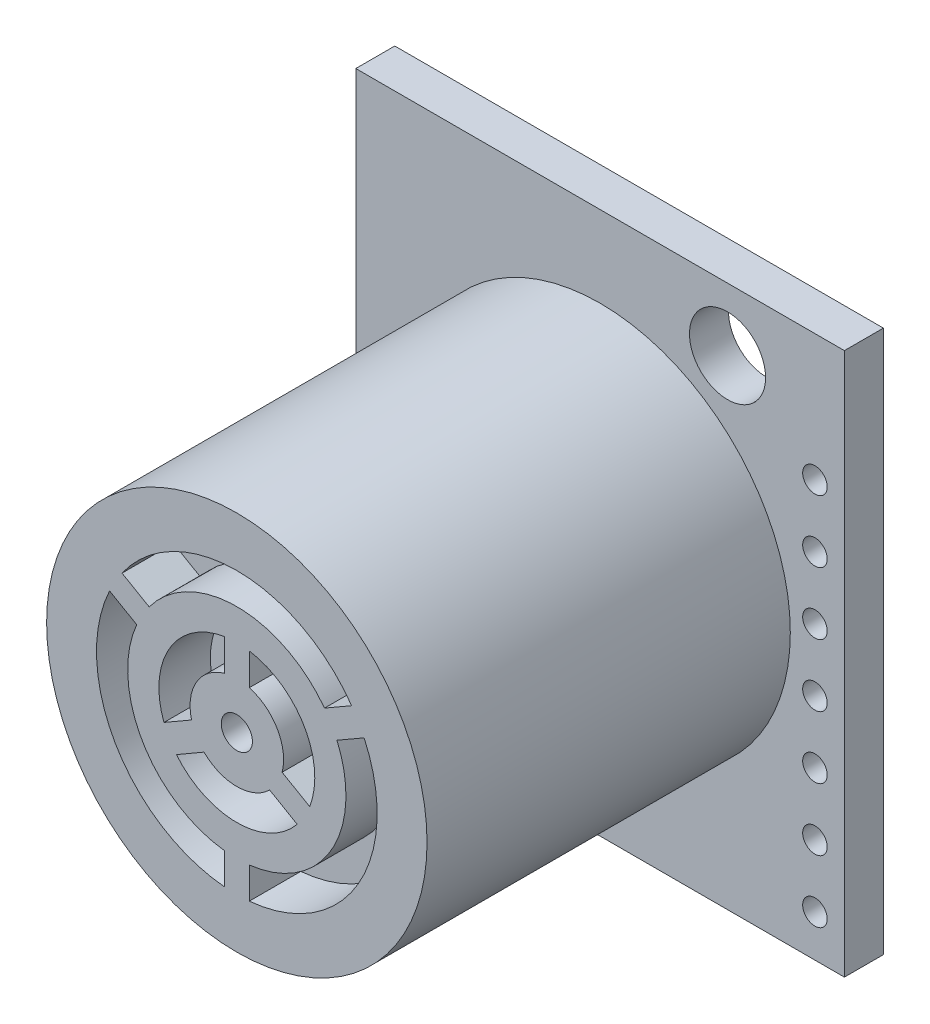
from build123d import *

# Parameters (mm, degrees)
SKETCH1_W          = 19.9
SKETCH1_H          = 22.1
EXTRUDE1_DEPTH     = 1.5875
SKETCH2_R          = 7.747
EXTRUDE2_DEPTH     = 14.7955
SKETCH3_R          = 0.635
EXTRUDE3_DEPTH     = 2.0955
SKETCH5_R          = 1.55
CUT_EXTRUDE1_DEPTH = 2.5875
SKETCH6_R          = 0.5
CUT_EXTRUDE2_DEPTH = 2.5875


with BuildPart() as part:
    # Sketch1 → Extrude1 (new body)
    with BuildSketch(Plane.XY):
        Rectangle(SKETCH1_W, SKETCH1_H)
    extrude(amount=EXTRUDE1_DEPTH)

    # Sketch5 → Cut-Extrude1 (cut, through all)
    with BuildSketch(Plane.XY.offset(1.5875)):
        with Locations((5.19, 8.49)):
            Circle(SKETCH5_R)
        with Locations((-7.41, -8.51)):
            Circle(SKETCH5_R)
    extrude(amount=-CUT_EXTRUDE1_DEPTH, mode=Mode.SUBTRACT)

    # Sketch6 → Cut-Extrude2 (cut, through all)
    with BuildSketch(Plane.XY.offset(1.5875)):
        with Locations((8.75, 5.89)):
            Circle(SKETCH6_R)
        with Locations((8.75, 3.35)):
            Circle(SKETCH6_R)
        with Locations((8.75, 0.81)):
            Circle(SKETCH6_R)
        with Locations((8.75, -1.73)):
            Circle(SKETCH6_R)
        with Locations((8.75, -4.27)):
            Circle(SKETCH6_R)
        with Locations((8.75, -6.81)):
            Circle(SKETCH6_R)
        with Locations((8.75, -9.35)):
            Circle(SKETCH6_R)
    extrude(amount=-CUT_EXTRUDE2_DEPTH, mode=Mode.SUBTRACT)


with BuildPart() as body_2:
    # Sketch2 → Extrude2 (new body)
    with BuildSketch(Plane.XY.offset(1.5875)):
        Circle(SKETCH2_R)
    extrude(amount=EXTRUDE2_DEPTH)

    # Sketch3 → Extrude3 (cut)
    with BuildSketch(Plane.XY.offset(16.383)):
        with BuildLine():
            Line((3.570260811, 2.647878914), (4.675743477, 3.286129629))
            ThreePointArc((4.675743477, 3.286129629), (0, 5.715), (-4.675743477, 3.286129629))
            Line((-4.675743477, 3.286129629), (-3.570260811, 2.647878914))
            ThreePointArc((-3.570260811, 2.647878914), (0, 4.445), (3.570260811, 2.647878914))
        make_face()
        with BuildLine():
            Line((-4.078260811, 1.767997104), (-5.183743477, 2.406247818))
            ThreePointArc((-5.183743477, 2.406247818), (-4.949335183, -2.8575), (-0.508, -5.692377447))
            Line((-0.508, -5.692377447), (-0.508, -4.415876017))
            ThreePointArc((-0.508, -4.415876017), (-3.84948292, -2.2225), (-4.078260811, 1.767997104))
        make_face()
        with BuildLine():
            Line((-0.508, 1.836017701), (-0.508, 3.134096521))
            ThreePointArc((-0.508, 3.134096521), (-2.749630657, 1.5875), (-2.968207205, -1.127107355))
            Line((-2.968207205, -1.127107355), (-1.844037971, -0.478067946))
            ThreePointArc((-1.844037971, -0.478067946), (-1.649778394, 0.9525), (-0.508, 1.836017701))
        make_face()
        with BuildLine():
            Line((-1.336037971, -1.357949756), (-2.460207205, -2.006989165))
            ThreePointArc((-2.460207205, -2.006989165), (0, -3.175), (2.460207205, -2.006989165))
            Line((2.460207205, -2.006989165), (1.336037971, -1.357949756))
            ThreePointArc((1.336037971, -1.357949756), (0, -1.905), (-1.336037971, -1.357949756))
        make_face()
        Circle(SKETCH3_R)
        with BuildLine():
            Line((1.844037971, -0.478067946), (2.968207205, -1.127107355))
            ThreePointArc((2.968207205, -1.127107355), (2.749630657, 1.5875), (0.508, 3.134096521))
            Line((0.508, 3.134096521), (0.508, 1.836017701))
            ThreePointArc((0.508, 1.836017701), (1.649778394, 0.9525), (1.844037971, -0.478067946))
        make_face()
        with BuildLine():
            ThreePointArc((0.508, -4.415876017), (3.84948292, -2.2225), (4.078260811, 1.767997104))
            Line((4.078260811, 1.767997104), (5.183743477, 2.406247818))
            ThreePointArc((5.183743477, 2.406247818), (4.949335183, -2.8575), (0.508, -5.692377447))
            Line((0.508, -5.692377447), (0.508, -4.415876017))
        make_face()
    extrude(amount=-EXTRUDE3_DEPTH, mode=Mode.SUBTRACT)


solid = Compound([part.part, body_2.part])
